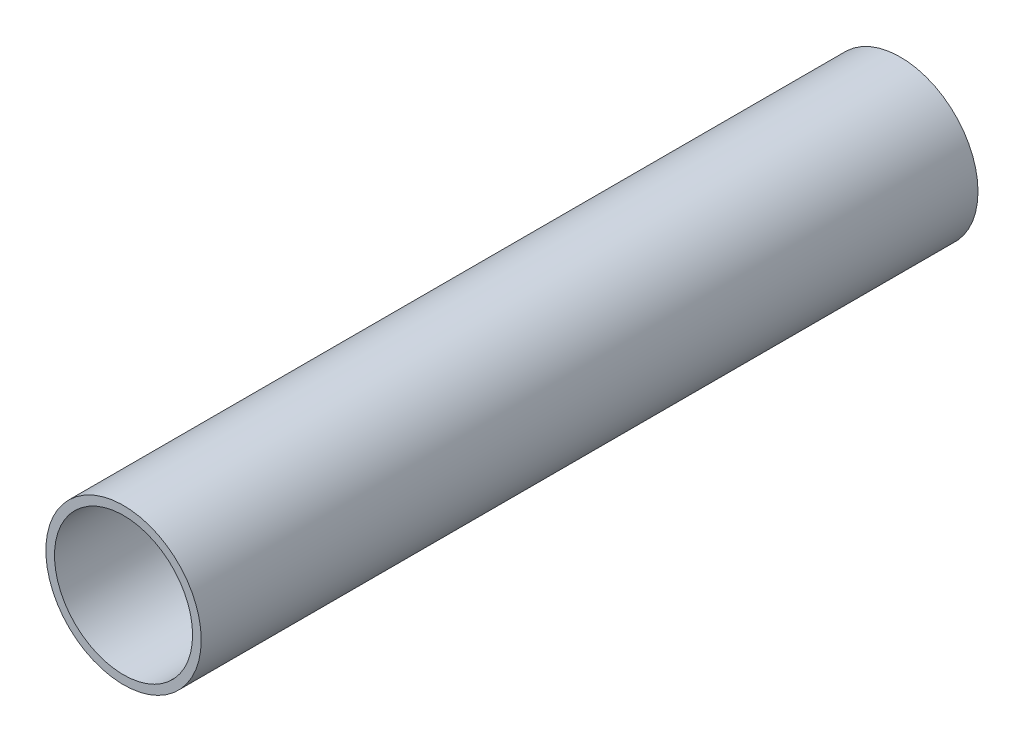
from build123d import *

# Parameters (mm, degrees)
SKETCH1_R           = 18
SKETCH1_R_2         = 16
BOSS_EXTRUDE1_DEPTH = 180


with BuildPart() as part:
    # Sketch1 → Boss-Extrude1 (new body)
    with BuildSketch(Plane.XY):
        Circle(SKETCH1_R)
        Circle(SKETCH1_R_2, mode=Mode.SUBTRACT)
    extrude(amount=BOSS_EXTRUDE1_DEPTH)


solid = part.part
